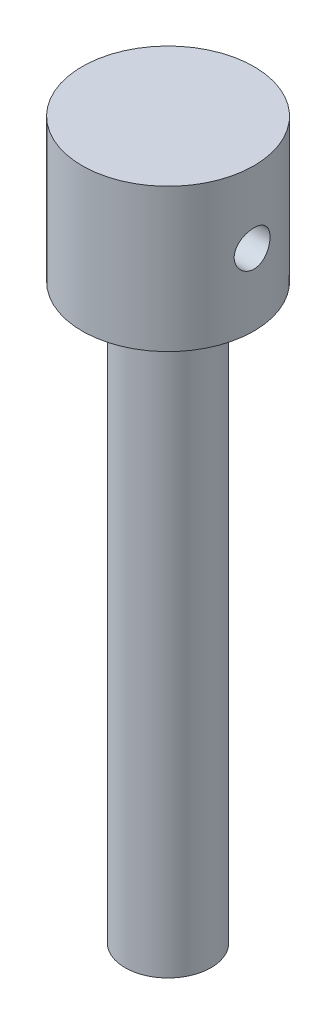
from build123d import *

# Parameters (mm, degrees)
SKETCH2_R          = 2.5
CUT_EXTRUDE1_DEPTH = 25


with BuildPart() as part:
    # Sketch1 → Revolve1 (revolve)
    with BuildSketch(Plane.XY):
        Polygon((0, 0), (6, 0), (6, 80), (12, 80), (12, 100), (0, 100), align=None)
    revolve(axis=Axis((0, -1000, 0), (0, 1, 0)))

    # Sketch2 → Cut-Extrude1 (cut, through all)
    with BuildSketch(Plane(origin=(12, 0, 0), x_dir=(0, 0, -1), z_dir=(1, 0, 0))):
        with Locations((0, 90)):
            Circle(SKETCH2_R)
    extrude(amount=-CUT_EXTRUDE1_DEPTH, mode=Mode.SUBTRACT)


solid = part.part
